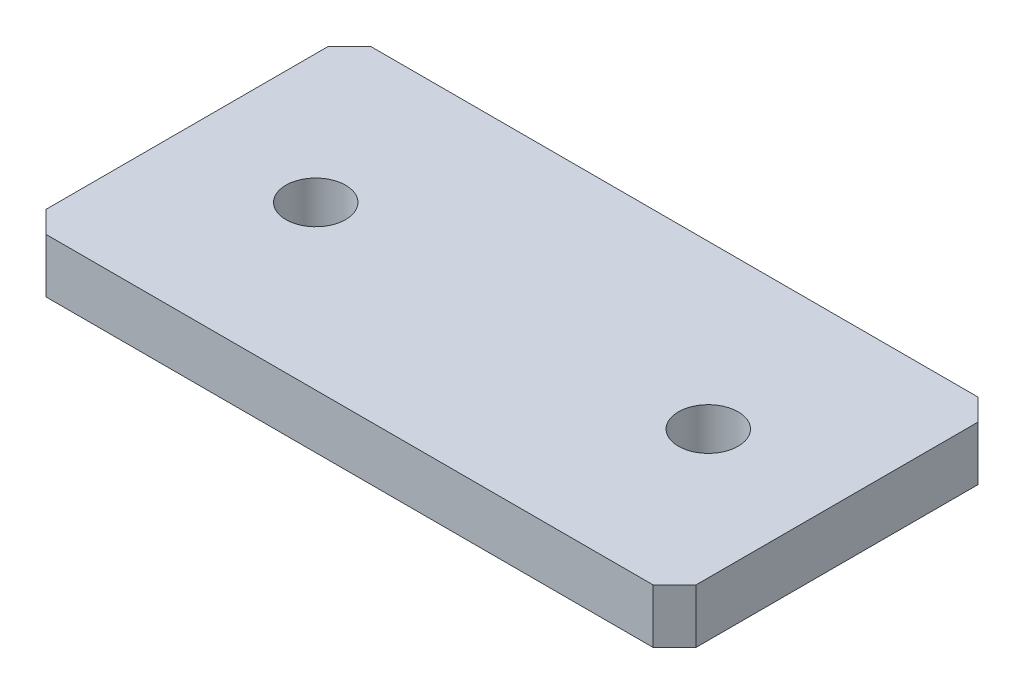
from build123d import *

# Parameters (mm, degrees)
SKETCH1_W            = 76.2
SKETCH1_H            = 38.1
BOSS_EXTRUDE1_DEPTH  = 6.35
M6_CLEARANCE_HOLE1_D = 7
CHAMFER1_SIZE        = 2.54


with BuildPart() as part:
    # Sketch1 → Boss-Extrude1 (new body)
    with BuildSketch(Plane(origin=(0, 0, 0), x_dir=(1, 0, 0), z_dir=(0, 1, 0))):
        Rectangle(SKETCH1_W, SKETCH1_H)
    extrude(amount=BOSS_EXTRUDE1_DEPTH)

    # M6 Clearance Hole1 (through all)
    with Locations(Plane(origin=(0, 6.35, 0), x_dir=(1, 0, 0), z_dir=(0, 1, 0))):
        with Locations((-22.999999974, 0), (22.999999974, 0)):
            Hole(M6_CLEARANCE_HOLE1_D / 2)

    # Chamfer1
    chamfer1_edges = [part.edges().sort_by_distance(p)[0] for p in [
        (38.1, 3.175, 19.05),
        (-38.1, 3.175, 19.05),
        (-38.1, 3.175, -19.05),
        (38.1, 3.175, -19.05),
    ]]
    chamfer(chamfer1_edges, length=CHAMFER1_SIZE)


solid = part.part
